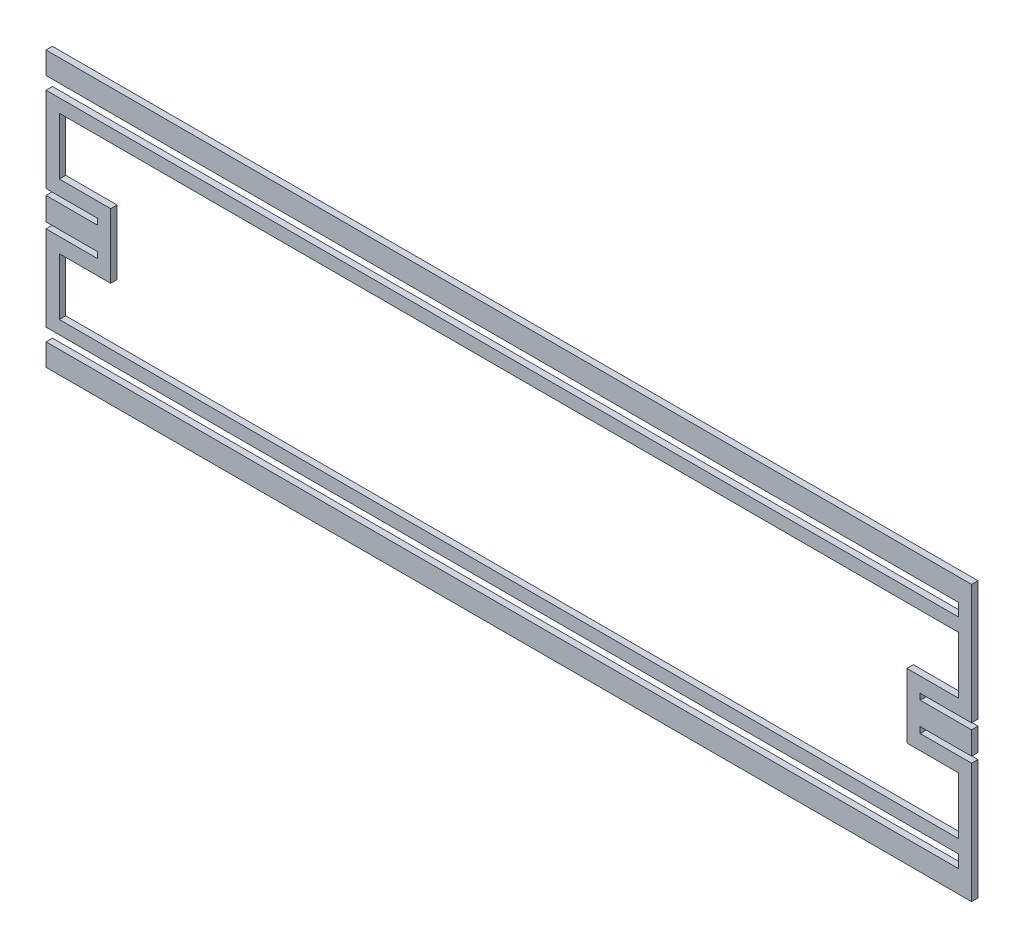
from build123d import *

# Parameters (mm, degrees)
BOSS_EXTRUDE1_DEPTH = 3.175


with BuildPart() as part:
    # Sketch1 → Boss-Extrude1 (new body)
    with BuildSketch(Plane.XY):
        Polygon((-228.7016, 8.62965), (-203.3016, 8.62965), (-203.3016, 5.65785), (-228.7016, 5.65785), (-228.7016, -5.65785), (-203.3016, -5.65785), (-203.3016, -8.62965), (-228.7016, -8.62965), (-228.7016, -50.70475), (222.1484, -50.70475), (222.1484, -56.97855), (-228.7016, -56.97855), (-228.7016, -67.897375), (228.7016, -67.897375), (228.7016, -8.62965), (203.3016, -8.62965), (203.3016, -5.65785), (228.7016, -5.65785), (228.7016, 5.65785), (203.3016, 5.65785), (203.3016, 8.62965), (228.7016, 8.62965), (228.7016, 67.897375), (-228.7016, 67.897375), (-228.7016, 56.97855), (222.1484, 56.97855), (222.1484, 50.70475), (-228.7016, 50.70475), align=None)
        Polygon((222.1484, -44.15155), (222.1484, -15.9766), (196.7484, -15.9766), (196.7484, 15.9766), (222.1484, 15.9766), (222.1484, 44.15155), (-222.1484, 44.15155), (-222.1484, 15.9766), (-196.7484, 15.9766), (-196.7484, -15.9766), (-222.1484, -15.9766), (-222.1484, -44.15155), align=None, mode=Mode.SUBTRACT)
    extrude(amount=BOSS_EXTRUDE1_DEPTH)


solid = part.part
